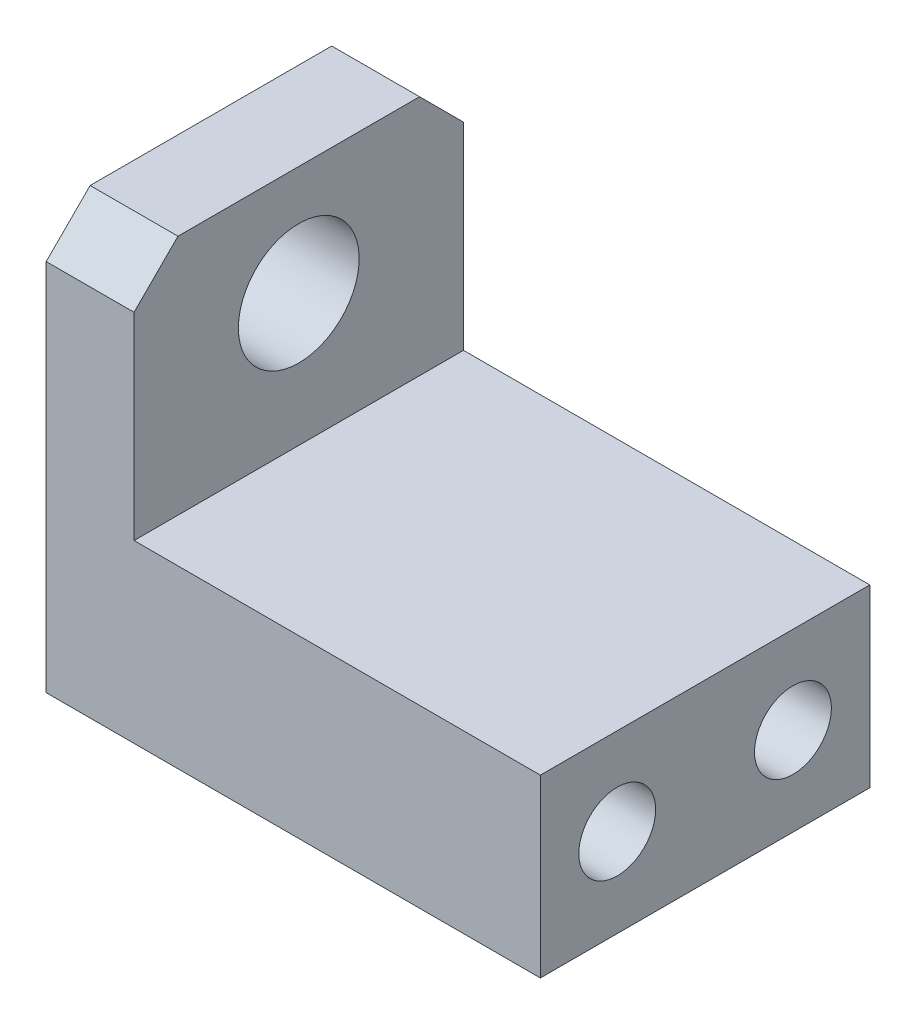
from build123d import *

# Parameters (mm, degrees)
BOSS_EXTRUDE1_DEPTH = 15
SKETCH2_R           = 2.75
SKETCH2_R_2         = 3
SKETCH2_R_3         = 1.75
CUT_EXTRUDE1_DEPTH  = 15
SKETCH3_R           = 1.75
CUT_EXTRUDE2_DEPTH  = 23.5
CHAMFER1_SIZE       = 2


with BuildPart() as part:
    # Sketch1 → Boss-Extrude1 (new body)
    with BuildSketch(Plane.XY):
        Polygon((-2.135338346, 2.060150376), (1.864661654, 2.060150376), (1.864661654, -8.939849624), (20.364661654, -8.939849624), (20.364661654, -16.939849624), (-2.135338346, -16.939849624), align=None)
    extrude(amount=BOSS_EXTRUDE1_DEPTH)

    # Sketch2 → Cut-Extrude1 (cut)
    with BuildSketch(Plane.ZY.offset(2.135338346)):
        with Locations((7.5, -2.939849624)):
            Circle(SKETCH2_R)
        with Locations((11.5, -12.914706032)):
            Circle(SKETCH2_R_2)
        with Locations((11.5, -12.914706032)):
            Circle(SKETCH2_R_3, mode=Mode.SUBTRACT)
        with Locations((3.5, -12.914706032)):
            Circle(SKETCH2_R_2)
        with Locations((3.5, -12.914706032)):
            Circle(SKETCH2_R_3, mode=Mode.SUBTRACT)
    extrude(amount=-CUT_EXTRUDE1_DEPTH, mode=Mode.SUBTRACT)

    # Sketch3 → Cut-Extrude2 (cut, through all)
    with BuildSketch(Plane.ZY.offset(2.135338346)):
        with Locations((3.5, -12.914706032)):
            Circle(SKETCH3_R)
        with Locations((11.5, -12.914706032)):
            Circle(SKETCH3_R)
    extrude(amount=-CUT_EXTRUDE2_DEPTH, mode=Mode.SUBTRACT)

    # Chamfer1
    chamfer1_edges = [part.edges().sort_by_distance(p)[0] for p in [
        (-0.135338346, 2.060150376, 15),
        (-0.135338346, 2.060150376, 0),
    ]]
    chamfer(chamfer1_edges, length=CHAMFER1_SIZE)


solid = part.part
